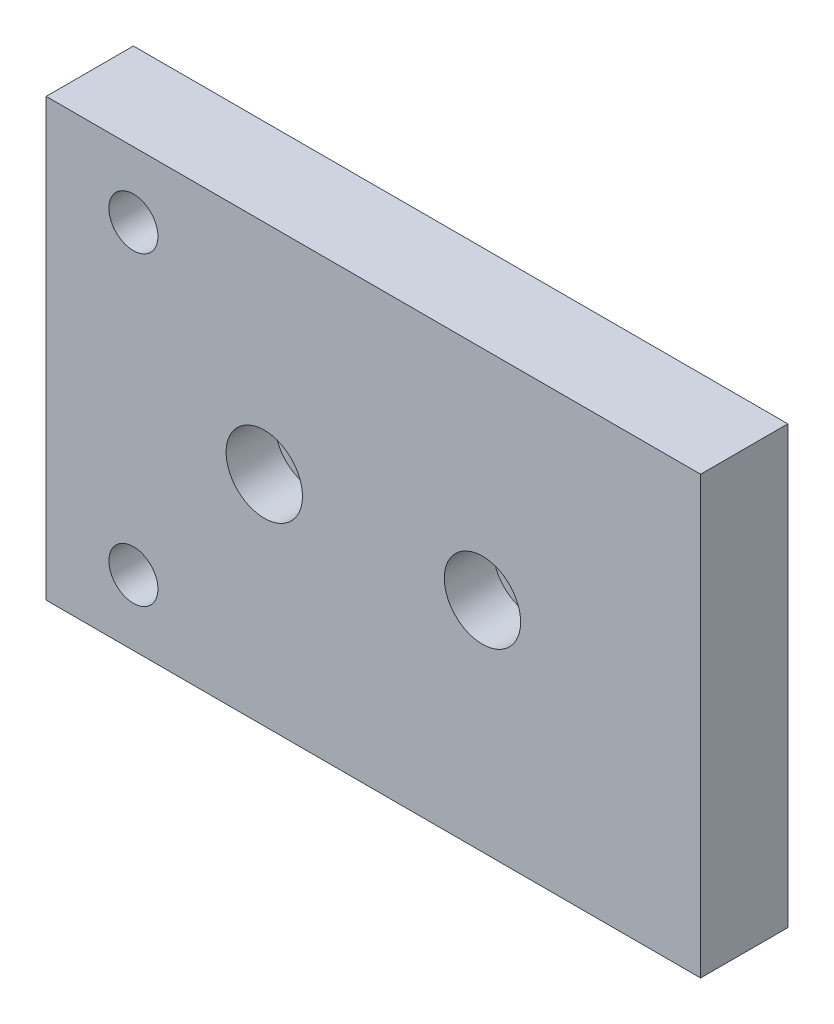
from build123d import *

# Parameters (mm, degrees)
SKETCH1_W                                        = 95.25
SKETCH1_H                                        = 63.5
BOSS_EXTRUDE1_DEPTH                              = 12.7
CBORE_FOR_1_4_SOCKET_HEAD_CAP_SCREW1_D           = 7.14248
CBORE_FOR_1_4_SOCKET_HEAD_CAP_SCREW1_CBORE_D     = 11.1125
CBORE_FOR_1_4_SOCKET_HEAD_CAP_SCREW1_CBORE_DEPTH = 6.35
CBORE_FOR_1_4_SOCKET_HEAD_CAP_SCREW2_D           = 7.14248
CBORE_FOR_1_4_SOCKET_HEAD_CAP_SCREW2_CBORE_D     = 11.1125
CBORE_FOR_1_4_SOCKET_HEAD_CAP_SCREW2_CBORE_DEPTH = 7.112


with BuildPart() as part:
    # Sketch1 → Boss-Extrude1 (new body)
    with BuildSketch(Plane.XY):
        with Locations((47.625, 31.75)):
            Rectangle(SKETCH1_W, SKETCH1_H)
    extrude(amount=BOSS_EXTRUDE1_DEPTH)

    # CBORE for 1/4 Socket Head Cap Screw1 (through all)
    with Locations(Plane(origin=(0, 0, 0), x_dir=(-1, 0, 0), z_dir=(0, 0, -1))):
        with Locations((-12.7, 53.975), (-12.7, 9.525)):
            CounterBoreHole(CBORE_FOR_1_4_SOCKET_HEAD_CAP_SCREW1_D / 2, CBORE_FOR_1_4_SOCKET_HEAD_CAP_SCREW1_CBORE_D / 2, CBORE_FOR_1_4_SOCKET_HEAD_CAP_SCREW1_CBORE_DEPTH)

    # CBORE for 1/4 Socket Head Cap Screw2 (through all)
    with Locations(Plane.XY.offset(12.7)):
        with Locations((31.75, 31.75), (63.5, 31.75)):
            CounterBoreHole(CBORE_FOR_1_4_SOCKET_HEAD_CAP_SCREW2_D / 2, CBORE_FOR_1_4_SOCKET_HEAD_CAP_SCREW2_CBORE_D / 2, CBORE_FOR_1_4_SOCKET_HEAD_CAP_SCREW2_CBORE_DEPTH)


solid = part.part
